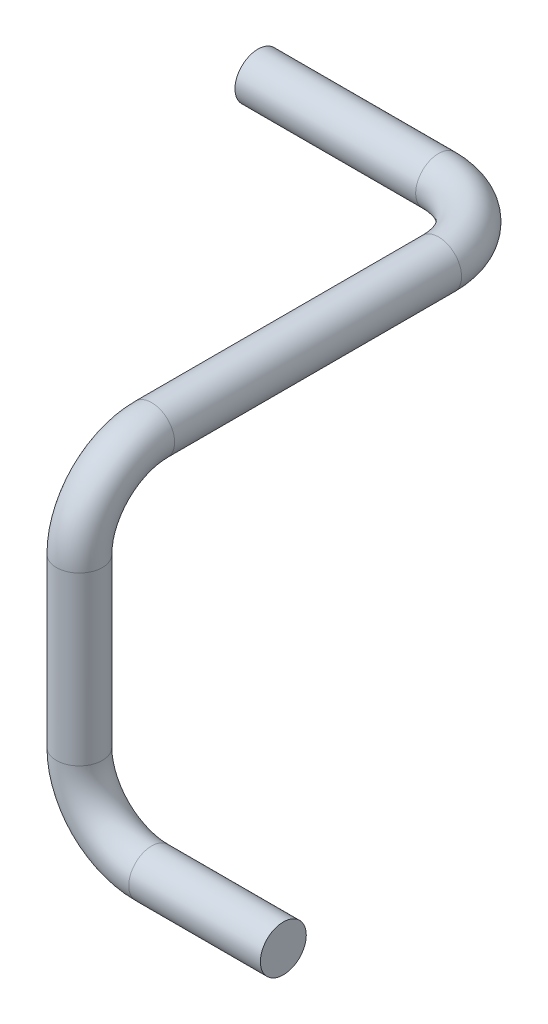
from build123d import *

# Parameters (mm, degrees)
CROQUIS2_R = 6.35
CROQUIS7_R = 6.35
CROQUIS8_R = 6.35


with BuildPart() as part:
    # Barrer2: sweep along a path in Croquis1
    with BuildLine(Plane(origin=(0, 0, 0), x_dir=(1, 0, 0), z_dir=(0, 1, 0))) as barrer2_path:
        Line((0, 0), (50, 0))
        ThreePointArc((50, 0), (64.142135624, -5.857864376), (70, -20))
        Line((70, -20), (70, -70))
    # Croquis2 → Barrer2 (sweep)
    with BuildSketch(Plane(origin=(0, 0, 0), x_dir=(0, 0, -1), z_dir=(1, 0, 0))):
        Circle(CROQUIS2_R)
    sweep(path=barrer2_path.line)

    # Barrer3: sweep along a path in Croquis3
    with BuildLine(Plane(origin=(70, 0, 0), x_dir=(0, 0, -1), z_dir=(1, 0, 0))) as barrer3_path:
        Line((-70, 0), (-99.387787897, 0))
        ThreePointArc((-99.387787897, 0), (-113.529923521, -5.857864376), (-119.387787897, -20))
        Line((-119.387787897, -20), (-119.387787897, -40.166140684))
        Line((-119.387787897, -40.166140684), (-119.387787897, -49.955998728))
    # Croquis7 → Barrer3 (sweep)
    with BuildSketch(Plane.XY.offset(70)):
        with Locations((70, 0)):
            Circle(CROQUIS7_R)
    sweep(path=barrer3_path.line)

    # Barrer4: sweep along a path in Croquis5
    with BuildLine(Plane.XY.offset(119.387787897)) as barrer4_path:
        Line((70, -49.842890924), (70, -66.211244979))
        ThreePointArc((70, -66.211244979), (75.857864376, -80.353380602), (90, -86.211244979))
        Line((90, -86.211244979), (126.42207306, -86.211244979))
    # Croquis8 → Barrer4 (sweep)
    with BuildSketch(Plane.XZ.offset(49.955998728)):
        with Locations((70, 119.387787897)):
            Circle(CROQUIS8_R)
    sweep(path=barrer4_path.line)


solid = part.part
